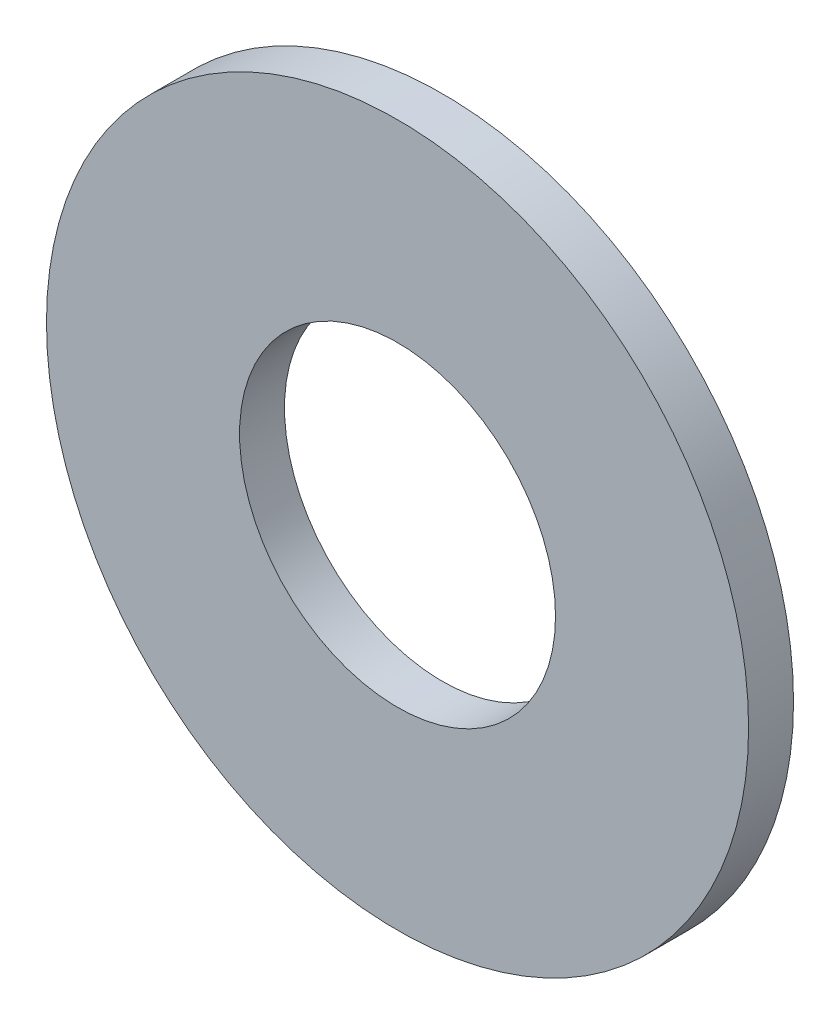
from build123d import *

# Parameters (mm, degrees)
SKETCH1_R      = 7.9375
SKETCH1_R_2    = 3.571875
EXTRUDE1_DEPTH = 1.016


with BuildPart() as part:
    # Sketch1 → Extrude1 (new body)
    with BuildSketch(Plane.XY):
        Circle(SKETCH1_R)
        Circle(SKETCH1_R_2, mode=Mode.SUBTRACT)
    extrude(amount=-EXTRUDE1_DEPTH)


solid = part.part
